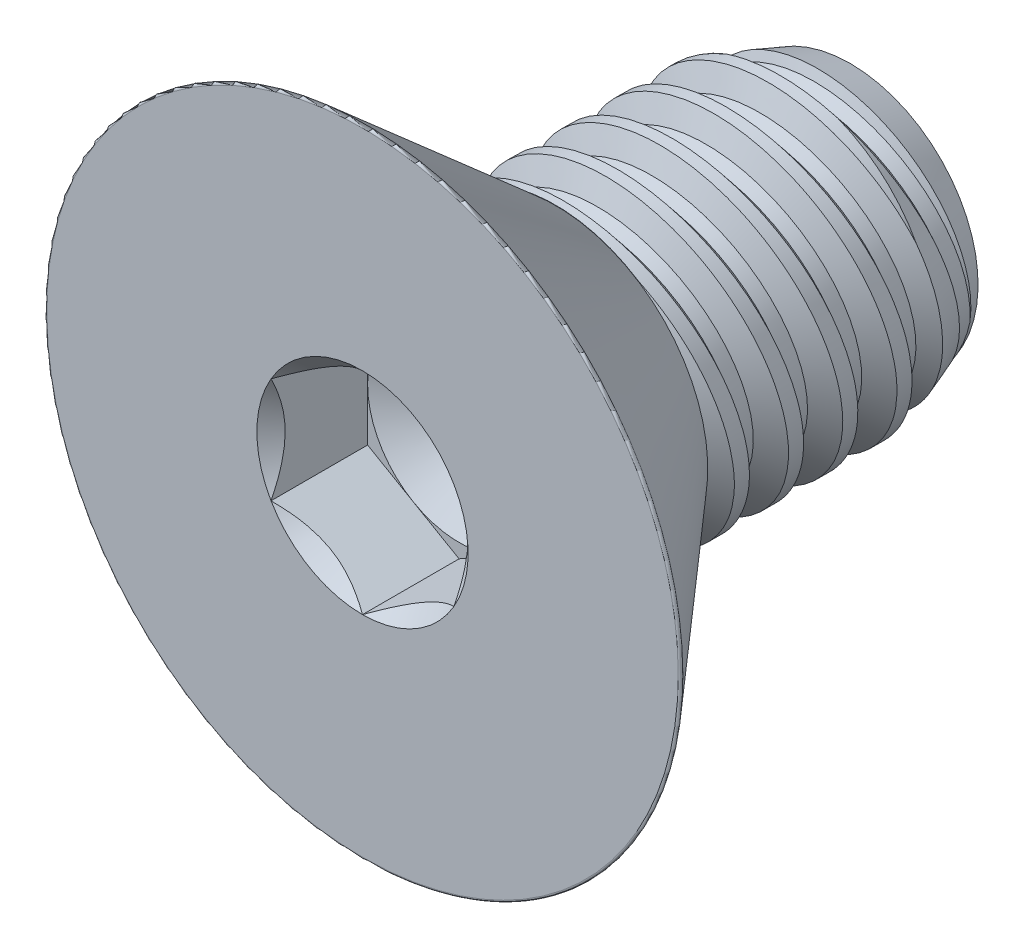
from build123d import *

# Parameters (mm, degrees)
SKETCH1_W          = 7.6708
SKETCH1_H          = 3.96875
LPATTERN1_COUNT    = 5
LPATTERN1_PITCH    = 1.411111111
LPATTERN2_COUNT    = 2
LPATTERN2_PITCH    = 1.411111111
SKETCH4_R          = 8.3312
EXTRUDE1_DEPTH     = 5.0292
FILLET1_R          = 0.0508
CUT_EXTRUDE1_DEPTH = 2.5146
SKETCH7_R          = 2.749630657
CUT_EXTRUDE4_DEPTH = 2.5146
CUT_EXTRUDE4_TAPER = 45
SKETCH8_R          = 2.38125
CUT_EXTRUDE5_DEPTH = 0.8382
CUT_EXTRUDE5_TAPER = 60


with BuildPart() as part:
    # Sketch1 → Revolve1 (revolve)
    with BuildSketch(Plane(origin=(0, 0, 0), x_dir=(0, 0, -1), z_dir=(1, 0, 0))):
        with Locations((3.8354, 1.984375)):
            Rectangle(SKETCH1_W, SKETCH1_H)
    revolve(axis=Axis((0, 0, 0), (0, 0, 1)))

    # Sketch2 → Cut-Revolve1 (revolve, cut)
    with BuildSketch(Plane(origin=(0, 0, 0), x_dir=(0, 0, -1), z_dir=(1, 0, 0))):
        Polygon((0.173665887, 3.999623935), (1.389327094, 4.215741483), (1.088850439, 3.386561296), (0.741518666, 3.324813425), align=None)
    cut_revolve1 = revolve(axis=Axis((0, -0.268755768, 0), (0, 0.175033335, -0.984562508)), mode=Mode.SUBTRACT)

    # Sketch3 → Cut-Revolve2 (revolve, cut)
    with BuildSketch(Plane(origin=(0, 0, 0), x_dir=(0, 0, -1), z_dir=(1, 0, 0))):
        Polygon((7.6708, 3.324813425), (5.901598802, 3.96875), (7.6708, 3.96875), align=None)
    revolve(axis=Axis((0, 0, -5.901598802), (0, 0, 1)), mode=Mode.SUBTRACT)

    # LPattern1: Cut-Revolve1 ×5
    with Locations(*[(0, 0, -i * LPATTERN1_PITCH) for i in range(1, LPATTERN1_COUNT)]):
        add(cut_revolve1, mode=Mode.SUBTRACT)

    # LPattern2: Cut-Revolve1 ×2
    with Locations(*[(0, 0, i * LPATTERN2_PITCH) for i in range(1, LPATTERN2_COUNT)]):
        add(cut_revolve1, mode=Mode.SUBTRACT)

    # Sketch4 → Extrude1 (add)
    with BuildSketch(Plane.XY):
        Circle(SKETCH4_R)
    extrude(amount=EXTRUDE1_DEPTH)

    # Sketch9 → Cut-Revolve3 (revolve, cut)
    with BuildSketch(Plane(origin=(0, 0, 0), x_dir=(0, 0, -1), z_dir=(1, 0, 0))):
        Polygon((-5.0292, 8.3312), (0, 3.959383138), (0, 8.3312), align=None)
    revolve(axis=Axis((0, 0, 0), (0, 0, 1)), mode=Mode.SUBTRACT)

    # Fillet1
    fillet1_edges = [part.edges().sort_by_distance(p)[0] for p in [
        (0, -8.3312, 5.0292),
    ]]
    fillet(fillet1_edges, radius=FILLET1_R)

    # Sketch6 → Cut-Extrude1 (cut)
    with BuildSketch(Plane.XY.offset(5.0292)):
        Polygon((0, -2.749630657), (2.38125, -1.374815329), (2.38125, 1.374815329), (0, 2.749630657), (-2.38125, 1.374815329), (-2.38125, -1.374815329), align=None)
    extrude(amount=-CUT_EXTRUDE1_DEPTH, mode=Mode.SUBTRACT)

    # Sketch7 → Cut-Extrude4 (cut)
    with BuildSketch(Plane.XY.offset(5.0292)):
        Circle(SKETCH7_R)
    extrude(amount=-CUT_EXTRUDE4_DEPTH, taper=CUT_EXTRUDE4_TAPER, mode=Mode.SUBTRACT)

    # Sketch8 → Cut-Extrude5 (cut)
    with BuildSketch(Plane.XY.offset(2.5146)):
        Circle(SKETCH8_R)
    extrude(amount=-CUT_EXTRUDE5_DEPTH, taper=CUT_EXTRUDE5_TAPER, mode=Mode.SUBTRACT)


solid = part.part
